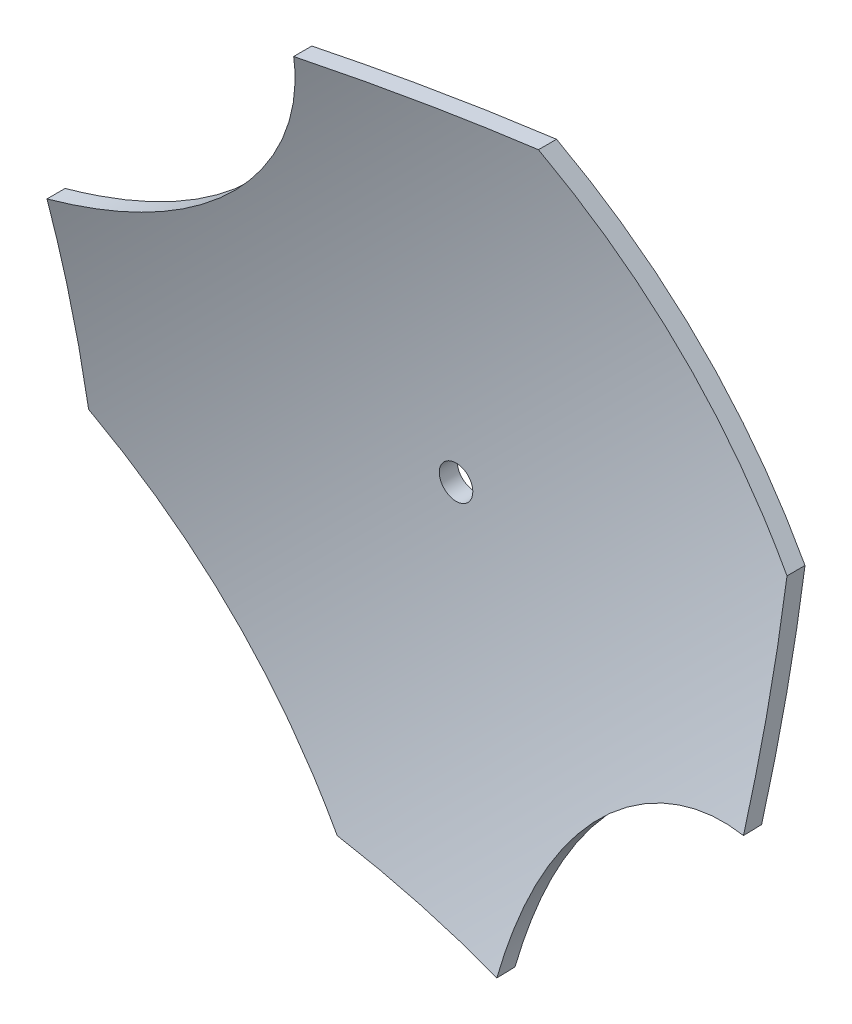
from build123d import *

# Parameters (mm, degrees)
SKETCH2_R           = 2.299249708
BOSS_EXTRUDE1_DEPTH = 12
SKETCH3_OUTSIDE_W   = 41.258
SKETCH3_OUTSIDE_H   = 165.023
CUT_EXTRUDE1_DEPTH  = 112.722871427


with BuildPart() as part:
    # Sketch2 → Boss-Extrude1 (new body)
    with BuildSketch(Plane.XY):
        with BuildLine():
            Line((-84.442352941, 11.083697479), (-50.442352941, -22.916302521))
            Line((-50.442352941, -22.916302521), (-22.442352941, -22.916302521))
            ThreePointArc((-22.442352941, -22.916302521), (-11.414384755, 0.055729293), (11.557647059, 11.083697479))
            Line((11.557647059, 11.083697479), (11.557647059, 39.083697479))
            Line((11.557647059, 39.083697479), (-22.442352941, 73.083697479))
            Line((-22.442352941, 73.083697479), (-50.442352941, 73.083697479))
            ThreePointArc((-50.442352941, 73.083697479), (-61.477304412, 50.118648949), (-84.442352941, 39.083697479))
            Line((-84.442352941, 39.083697479), (-84.442352941, 11.083697479))
        make_face()
        with Locations((-36.442352941, 25.083697479)):
            Circle(SKETCH2_R, mode=Mode.SUBTRACT)
    extrude(amount=-BOSS_EXTRUDE1_DEPTH)

    # Sketch3 outside → Cut-Extrude1 (cut, through all)
    with BuildSketch(Plane(origin=(25.320672269, 25.320672269, 0), x_dir=(0, 0, -1), z_dir=(0.707106781, 0.707106781, 0))):
        with Locations((6, 43.5055)):
            Rectangle(SKETCH3_OUTSIDE_W, SKETCH3_OUTSIDE_H)
        with BuildLine():
            Line((0, 87.346107905), (2.5, 87.346107905))
            add(Edge.make_bspline(
                [(2.5, -0.291956117), (19.268904304, 41.792164318), (2.5, 87.346107905)],
                knots=[0, 0, 0, 0.999526324, 0.999526324, 0.999526324], degree=2))
            Line((2.5, -0.291956117), (0, -0.335132962))
            add(Edge.make_bspline(
                [(0, -0.335132962), (16.792759748, 41.768931155), (0, 87.346107905)],
                knots=[0, 0, 0, 1, 1, 1], degree=2))
        make_face(mode=Mode.SUBTRACT)
    extrude(amount=-CUT_EXTRUDE1_DEPTH, mode=Mode.SUBTRACT)


solid = part.part
